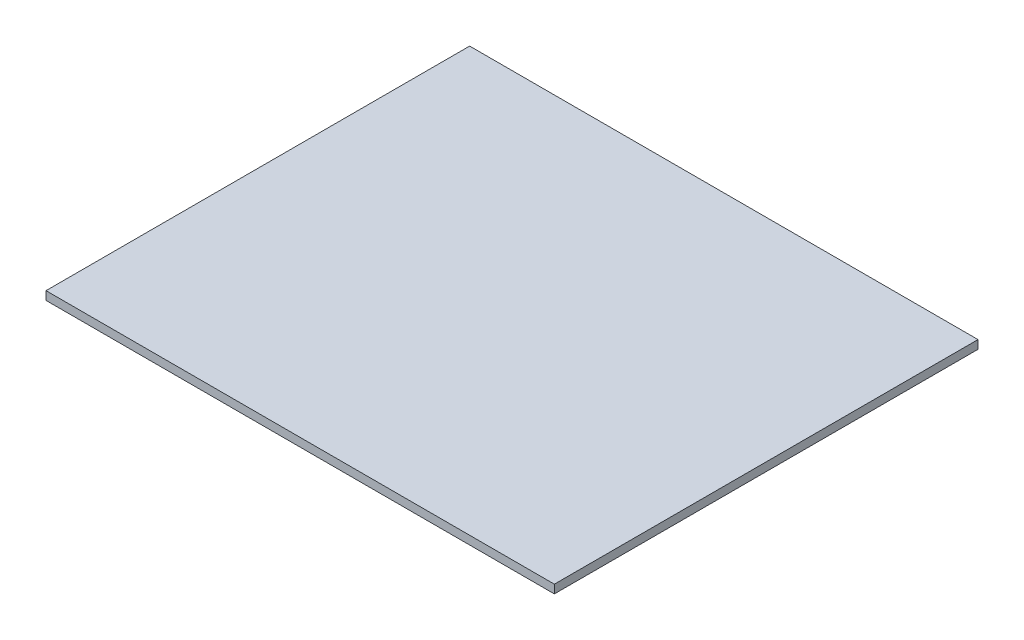
from build123d import *

# Parameters (mm, degrees)
SKETCH1_W           = 1.2
SKETCH1_H           = 1
BOSS_EXTRUDE1_DEPTH = 0.02


with BuildPart() as part:
    # Sketch1 → Boss-Extrude1 (new body)
    with BuildSketch(Plane(origin=(0, 0, 0), x_dir=(1, 0, 0), z_dir=(0, 1, 0))):
        Rectangle(SKETCH1_W, SKETCH1_H)
    extrude(amount=BOSS_EXTRUDE1_DEPTH)


solid = part.part
